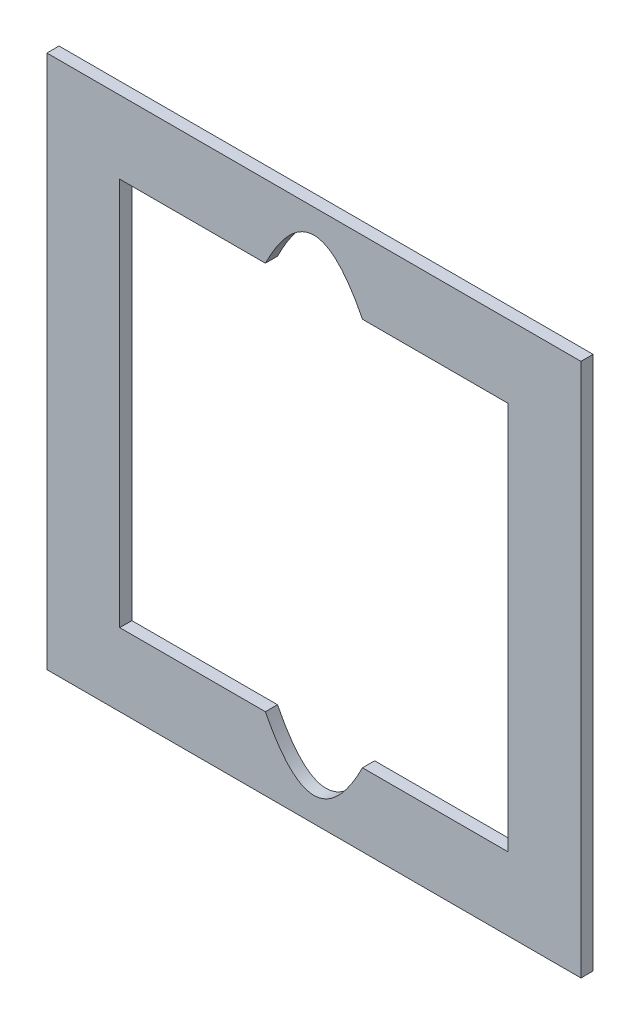
from build123d import *

# Parameters (mm, degrees)
SKETCH1_W           = 139.7
SKETCH1_H           = 139.7
BOSS_EXTRUDE1_DEPTH = 3.175


with BuildPart() as part:
    # Sketch1 → Boss-Extrude1 (new body)
    with BuildSketch(Plane.XY):
        with Locations((69.85, 69.85)):
            Rectangle(SKETCH1_W, SKETCH1_H)
        with BuildLine():
            Line((19.05, 120.65), (57.15, 120.65))
            add(Edge.make_bspline(
                [(57.15, 120.65), (69.85, 146.05), (82.55, 120.65)],
                knots=[0, 0, 0, 1, 1, 1], degree=2))
            Line((82.55, 120.65), (120.65, 120.65))
            Line((120.65, 120.65), (120.65, 19.05))
            Line((120.65, 19.05), (82.55, 19.05))
            add(Edge.make_bspline(
                [(57.15, 19.05), (69.85, -6.155350719), (82.55, 19.05)],
                knots=[0, 0, 0, 1, 1, 1], degree=2))
            Line((57.15, 19.05), (19.05, 19.05))
            Line((19.05, 19.05), (19.05, 120.65))
        make_face(mode=Mode.SUBTRACT)
    extrude(amount=BOSS_EXTRUDE1_DEPTH)


solid = part.part
